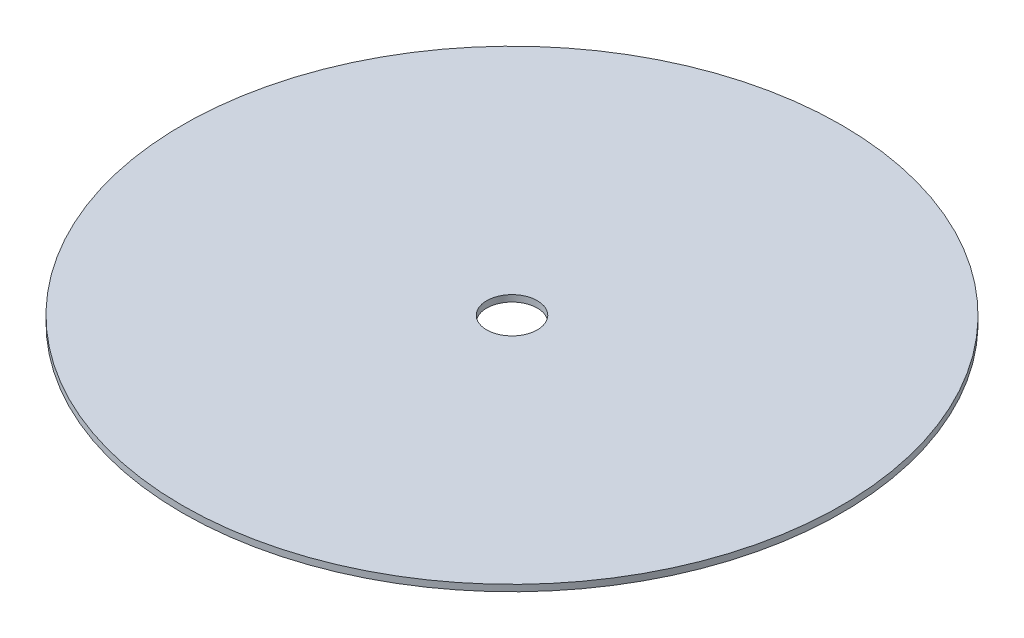
from build123d import *

# Parameters (mm, degrees)
SKETCH2_R           = 153
SKETCH2_R_2         = 11.75
BOSS_EXTRUDE1_DEPTH = 3


with BuildPart() as part:
    # Sketch2 → Boss-Extrude1 (new body)
    with BuildSketch(Plane(origin=(0, 0, 0), x_dir=(1, 0, 0), z_dir=(0, 1, 0))):
        Circle(SKETCH2_R)
        Circle(SKETCH2_R_2, mode=Mode.SUBTRACT)
    extrude(amount=BOSS_EXTRUDE1_DEPTH)


solid = part.part
